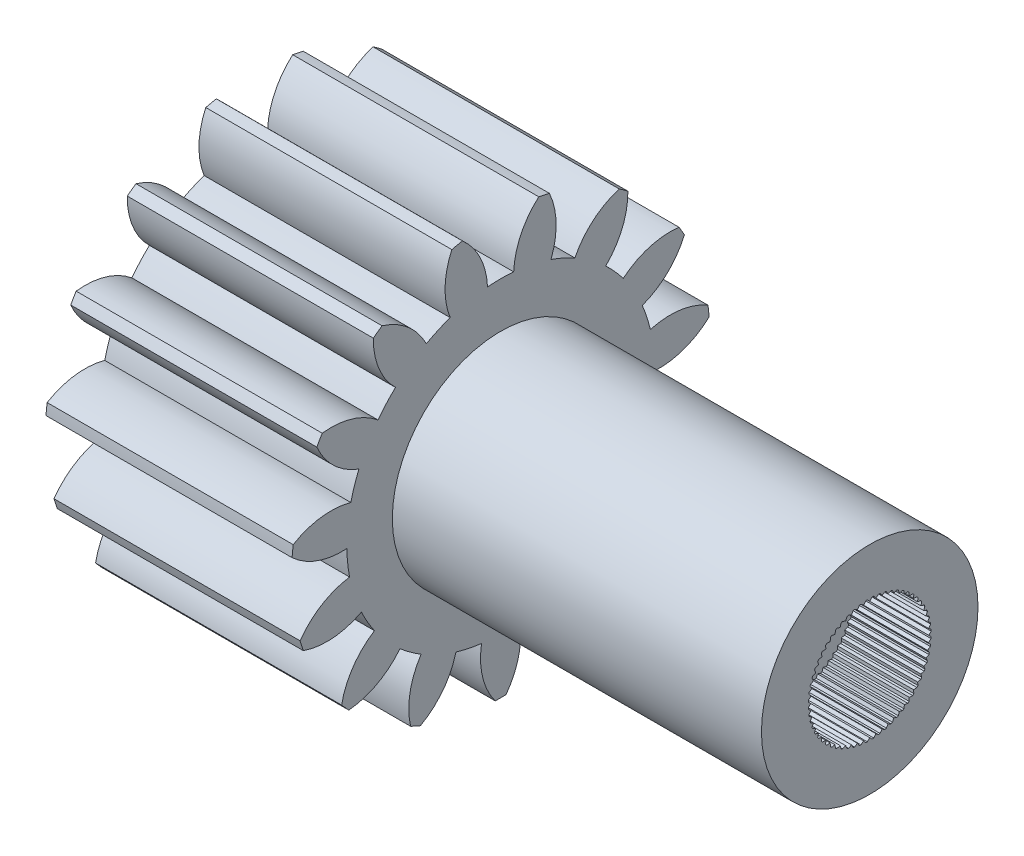
from build123d import *

# Parameters (mm, degrees)
BASPROSKE_W         = 10
BASPROSKE_H         = 8.5
TOOTHCUT_DEPTH      = 16.636495771
TEETHCUTS_COUNT     = 15
TEETHCUTS_ANGLE     = 336
BORSKE_R            = 2.5
BORE_DEPTH          = 50.0000508
BOSS_EXTRUDE1_START = 15
SKETCH1_R           = 4.4
SKETCH1_R_2         = 2.5
BOSS_EXTRUDE1_DEPTH = 15
BOSS_EXTRUDE2_DEPTH = 3.1
CIRPATTERN1_COUNT   = 60
SKETCH4_R           = 2.5
SKETCH4_R_2         = 0.85
BOSS_EXTRUDE3_DEPTH = 0.5
SKETCH5_R           = 3.5
CUT_EXTRUDE1_DEPTH  = 21


with BuildPart() as part:
    # BasProSke → Base-Revolve (revolve)
    with BuildSketch(Plane(origin=(0, 0, 0), x_dir=(1, 0, 0), z_dir=(0, 1, 0))):
        with Locations((5, 4.25)):
            Rectangle(BASPROSKE_W, BASPROSKE_H)
    revolve(axis=Axis((-10, 0, 0), (1, 0, 0)))

    # TooCutSke → ToothCut (cut, through all)
    with BuildSketch(Plane(origin=(0, 0, 0), x_dir=(0, 0, -1), z_dir=(1, 0, 0))):
        with BuildLine():
            ThreePointArc((0.531576138, 6.226349477), (0, 6.249), (-0.531576138, 6.226349477))
            ThreePointArc((-0.531576138, 6.226349477), (-0.830301624, 7.411024729), (-1.576608494, 8.378350125))
            ThreePointArc((-1.576608494, 8.378350125), (0, 8.5254), (1.576608494, 8.378350125))
            ThreePointArc((1.576608494, 8.378350125), (0.830301624, 7.411024729), (0.531576138, 6.226349477))
        make_face()
    toothcut = extrude(amount=TOOTHCUT_DEPTH, mode=Mode.SUBTRACT)

    # TeethCuts: ToothCut ×15 about axis
    teethcuts_axis = Axis((-10, 0, 0), (1, 0, 0))
    for i in range(1, TEETHCUTS_COUNT):
        add(toothcut.rotate(teethcuts_axis, i * TEETHCUTS_ANGLE / (TEETHCUTS_COUNT - 1)), mode=Mode.SUBTRACT)

    # BorSke → Bore (cut, symmetric)
    with BuildSketch(Plane(origin=(0, 0, 0), x_dir=(0, 0, -1), z_dir=(1, 0, 0))):
        Circle(BORSKE_R)
    extrude(amount=BORE_DEPTH, both=True, mode=Mode.SUBTRACT)

    # Sketch1 → Boss-Extrude1 (add)
    with BuildSketch(Plane(origin=(10, 0, 0), x_dir=(0, 0, -1), z_dir=(1, 0, 0)).offset(BOSS_EXTRUDE1_START)):
        Circle(SKETCH1_R)
        Circle(SKETCH1_R_2, mode=Mode.SUBTRACT)
    extrude(amount=-BOSS_EXTRUDE1_DEPTH)

    # Sketch2 → Boss-Extrude2 (add)
    with BuildSketch(Plane(origin=(25, 0, 0), x_dir=(0, 0, -1), z_dir=(1, 0, 0))):
        with BuildLine():
            ThreePointArc((0.098075499, 2.498075499), (0, 2.5), (-0.098075499, 2.498075499))
            Line((-0.098075499, 2.498075499), (0, 2.4))
            Line((0, 2.4), (0.098075499, 2.498075499))
        make_face()
    boss_extrude2 = extrude(amount=-BOSS_EXTRUDE2_DEPTH)

    # CirPattern1: Boss-Extrude2 ×60 about axis
    cirpattern1_axis = Axis((25, 0, 0), (-1, 0, 0))
    for i in range(1, CIRPATTERN1_COUNT):
        add(boss_extrude2.rotate(cirpattern1_axis, i * 360 / CIRPATTERN1_COUNT))

    # Sketch4 → Boss-Extrude3 (add)
    with BuildSketch(Plane(origin=(21.9, 0, 0), x_dir=(0, 0, -1), z_dir=(1, 0, 0))):
        Circle(SKETCH4_R)
        Circle(SKETCH4_R_2, mode=Mode.SUBTRACT)
    extrude(amount=-BOSS_EXTRUDE3_DEPTH)

    # Sketch5 → Cut-Extrude1 (cut)
    with BuildSketch(Plane.ZY):
        Circle(SKETCH5_R)
    extrude(amount=-CUT_EXTRUDE1_DEPTH, mode=Mode.SUBTRACT)


solid = part.part
